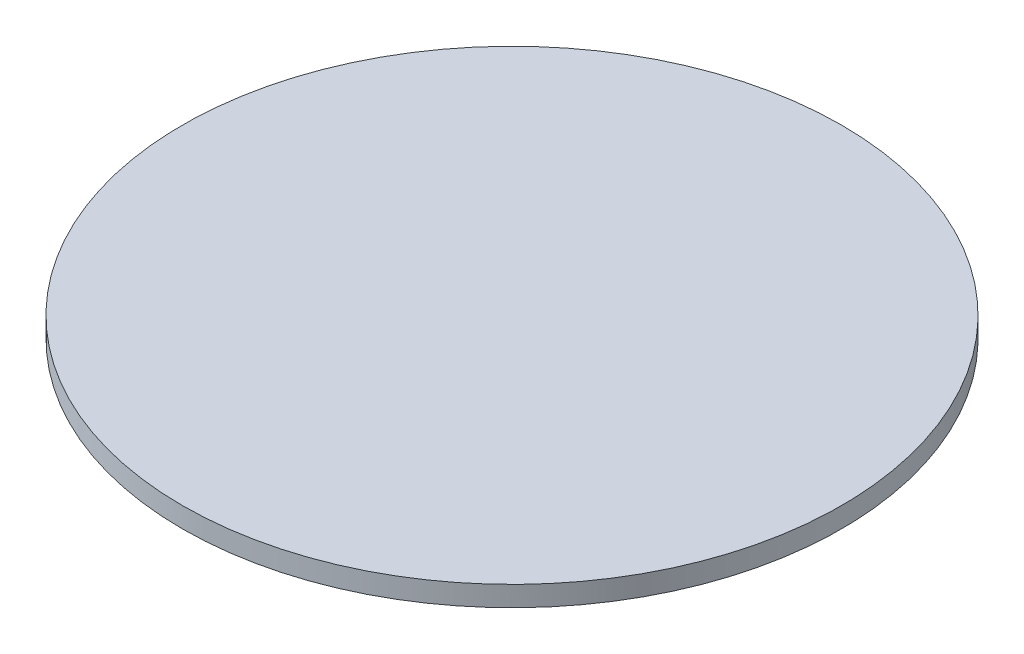
from build123d import *

# Parameters (mm, degrees)
SKETCH1_R           = 16.3
BOSS_EXTRUDE1_DEPTH = 1


with BuildPart() as part:
    # Sketch1 → Boss-Extrude1 (new body)
    with BuildSketch(Plane(origin=(0, 0, 0), x_dir=(1, 0, 0), z_dir=(0, 1, 0))):
        Circle(SKETCH1_R)
    extrude(amount=BOSS_EXTRUDE1_DEPTH)


solid = part.part
